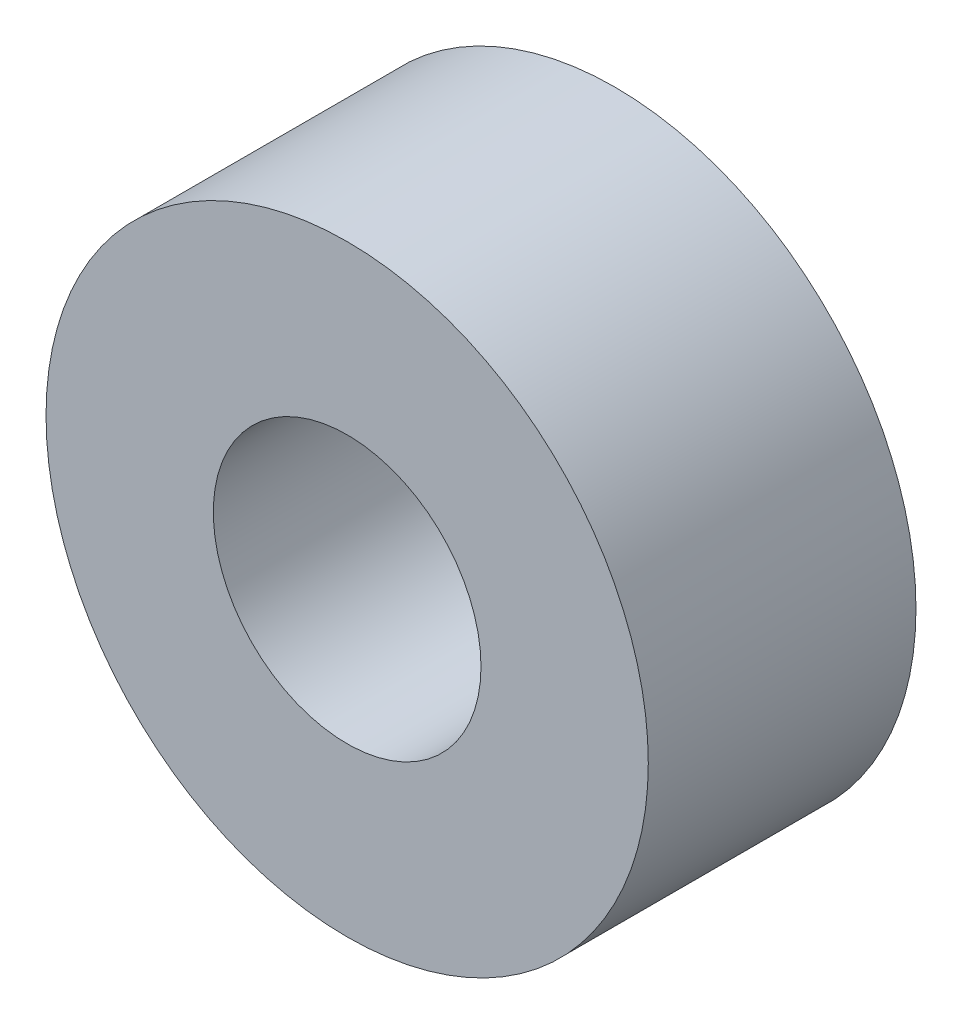
from build123d import *

# Parameters (mm, degrees)
SKETCH_1_R      = 4.5
SKETCH_1_R_2    = 2
EXTRUDE_1_DEPTH = 4


with BuildPart() as part:
    # 草图1 → 凸台-拉伸1 (new body)
    with BuildSketch(Plane.XY):
        Circle(SKETCH_1_R)
        Circle(SKETCH_1_R_2, mode=Mode.SUBTRACT)
    extrude(amount=EXTRUDE_1_DEPTH)


solid = part.part
